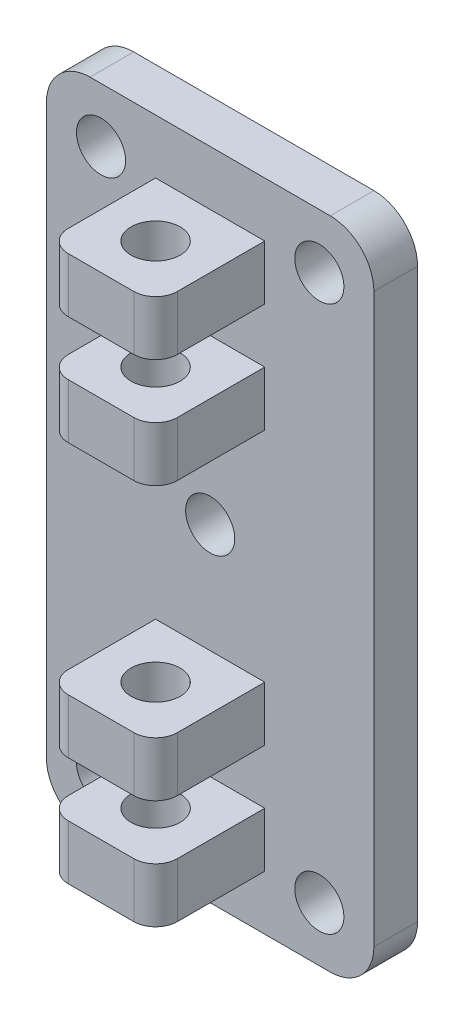
from build123d import *

# Parameters (mm, degrees)
ESQUISSE1_W             = 30
ESQUISSE1_H             = 60
BOSS_EXTRU_1_DEPTH      = 4
ESQUISSE2_W             = 10
ESQUISSE2_H             = 5
BOSS_EXTRU_2_DEPTH      = 10
ESQUISSE3_R             = 2.25
ENL_V_MAT_EXTRU_1_DEPTH = 56
CONG_1_R                = 2
CONG_2_R                = 4
ESQUISSE4_R             = 2.25
ENL_V_MAT_EXTRU_2_DEPTH = 5


with BuildPart() as part:
    # Esquisse1 → Boss.-Extru.1 (new body)
    with BuildSketch(Plane.XY):
        with Locations((-15, 30)):
            Rectangle(ESQUISSE1_W, ESQUISSE1_H)
    extrude(amount=BOSS_EXTRU_1_DEPTH)

    # Esquisse2 → Boss.-Extru.2 (add)
    with BuildSketch(Plane.XY.offset(4)):
        with Locations((-15, 52.5)):
            Rectangle(ESQUISSE2_W, ESQUISSE2_H)
        with Locations((-15, 42.5)):
            Rectangle(ESQUISSE2_W, ESQUISSE2_H)
        with Locations((-15, 17.5)):
            Rectangle(ESQUISSE2_W, ESQUISSE2_H)
        with Locations((-15, 7.5)):
            Rectangle(ESQUISSE2_W, ESQUISSE2_H)
    extrude(amount=BOSS_EXTRU_2_DEPTH)

    # Esquisse3 → Enlèv. mat.-Extru.1 (cut, through all)
    with BuildSketch(Plane.XZ.offset(-5)):
        with Locations(Location((-15, 9, 0), (0, 0, 270))):  # turned: the seam where the file's is
            Circle(ESQUISSE3_R)
    extrude(amount=-ENL_V_MAT_EXTRU_1_DEPTH, mode=Mode.SUBTRACT)

    # Congé1
    cong_1_edges = [part.edges().sort_by_distance(p)[0] for p in [
        (-20, 52.5, 14),
        (-10, 52.5, 14),
        (-20, 42.5, 14),
        (-10, 42.5, 14),
        (-20, 17.5, 14),
        (-10, 17.5, 14),
        (-20, 7.5, 14),
        (-10, 7.5, 14),
    ]]
    fillet(cong_1_edges, radius=CONG_1_R)

    # Congé2
    cong_2_edges = [part.edges().sort_by_distance(p)[0] for p in [
        (-30, 60, 2),
        (0, 60, 2),
        (0, 0, 2),
        (-30, 0, 2),
    ]]
    fillet(cong_2_edges, radius=CONG_2_R)

    # Esquisse4 → Enlèv. mat.-Extru.2 (cut, through all)
    with BuildSketch(Plane.XY.offset(4)):
        with Locations((-5, 55)):
            Circle(ESQUISSE4_R)
        with Locations((-25, 55)):
            Circle(ESQUISSE4_R)
        with Locations((-5, 5)):
            Circle(ESQUISSE4_R)
        with Locations((-25, 5)):
            Circle(ESQUISSE4_R)
        with Locations((-15, 30)):
            Circle(ESQUISSE4_R)
    extrude(amount=-ENL_V_MAT_EXTRU_2_DEPTH, mode=Mode.SUBTRACT)


solid = part.part
